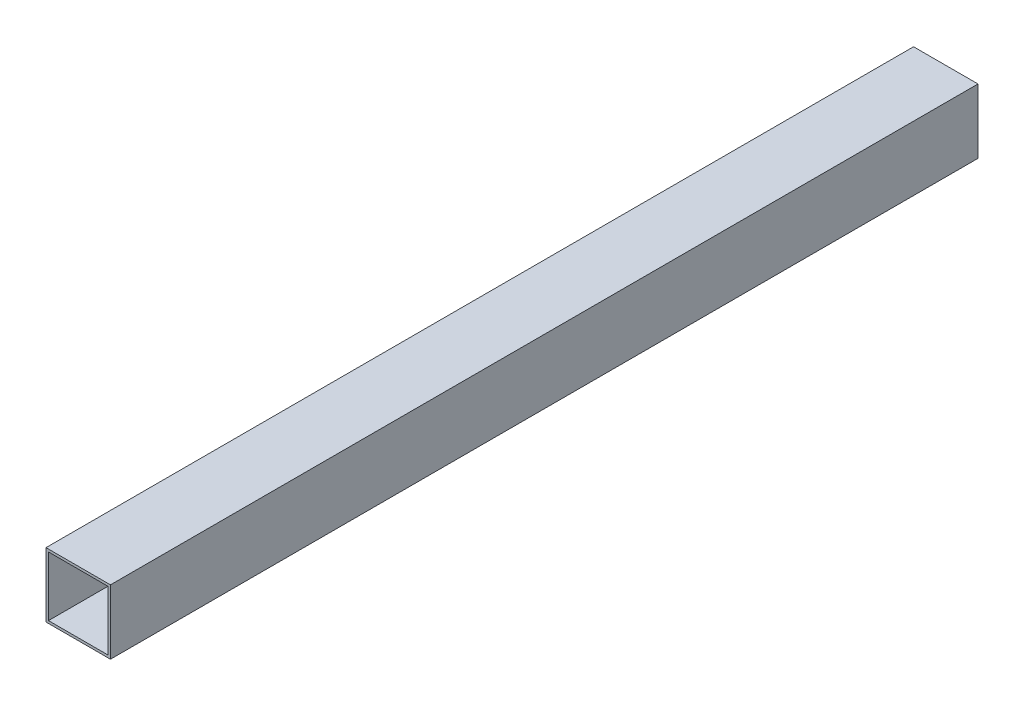
from build123d import *

# Parameters (mm, degrees)
SKETCH1_W           = 79.248
SKETCH1_H           = 79.248
SKETCH1_W_2         = 73.152
SKETCH1_H_2         = 73.152
BOSS_EXTRUDE1_DEPTH = 1066.8


with BuildPart() as part:
    # Sketch1 → Boss-Extrude1 (new body)
    with BuildSketch(Plane.XY):
        Rectangle(SKETCH1_W, SKETCH1_H)
        Rectangle(SKETCH1_W_2, SKETCH1_H_2, mode=Mode.SUBTRACT)
    extrude(amount=BOSS_EXTRUDE1_DEPTH)


solid = part.part
